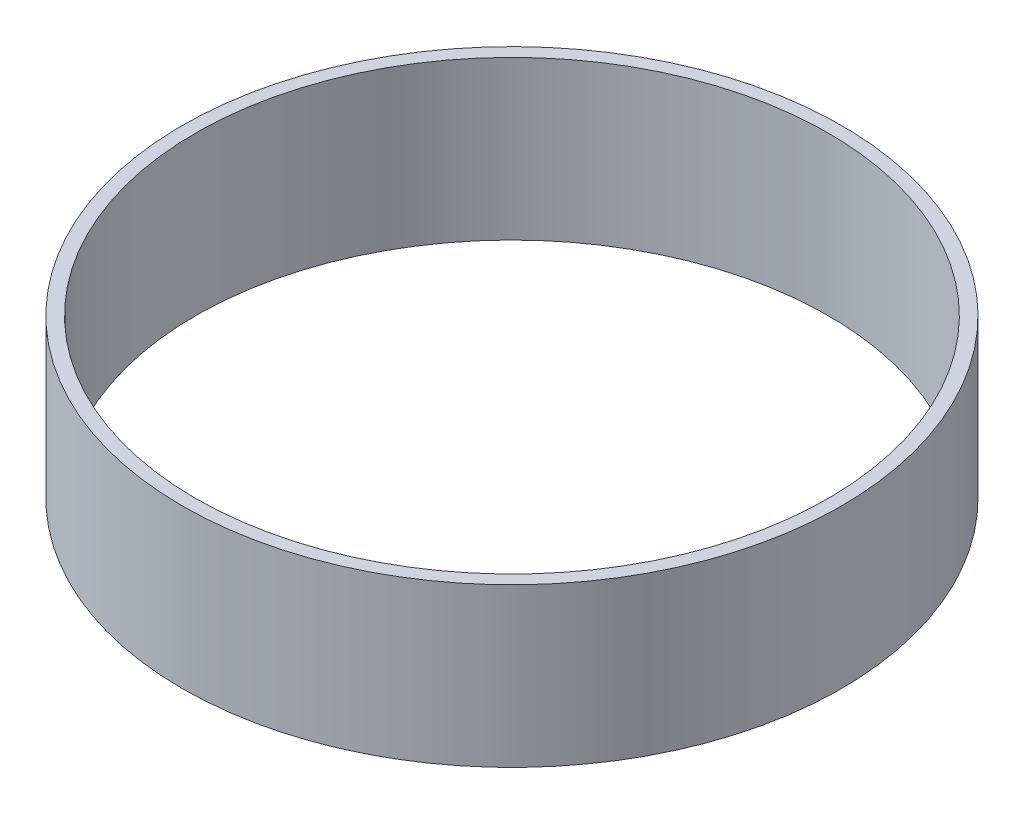
from build123d import *

# Parameters (mm, degrees)
SKETCH1_R           = 158.75
SKETCH1_R_2         = 152.4
BOSS_EXTRUDE1_DEPTH = 76.2


with BuildPart() as part:
    # Sketch1 → Boss-Extrude1 (new body)
    with BuildSketch(Plane(origin=(0, 0, 0), x_dir=(1, 0, 0), z_dir=(0, 1, 0))):
        Circle(SKETCH1_R)
        Circle(SKETCH1_R_2, mode=Mode.SUBTRACT)
    extrude(amount=-BOSS_EXTRUDE1_DEPTH)


solid = part.part
